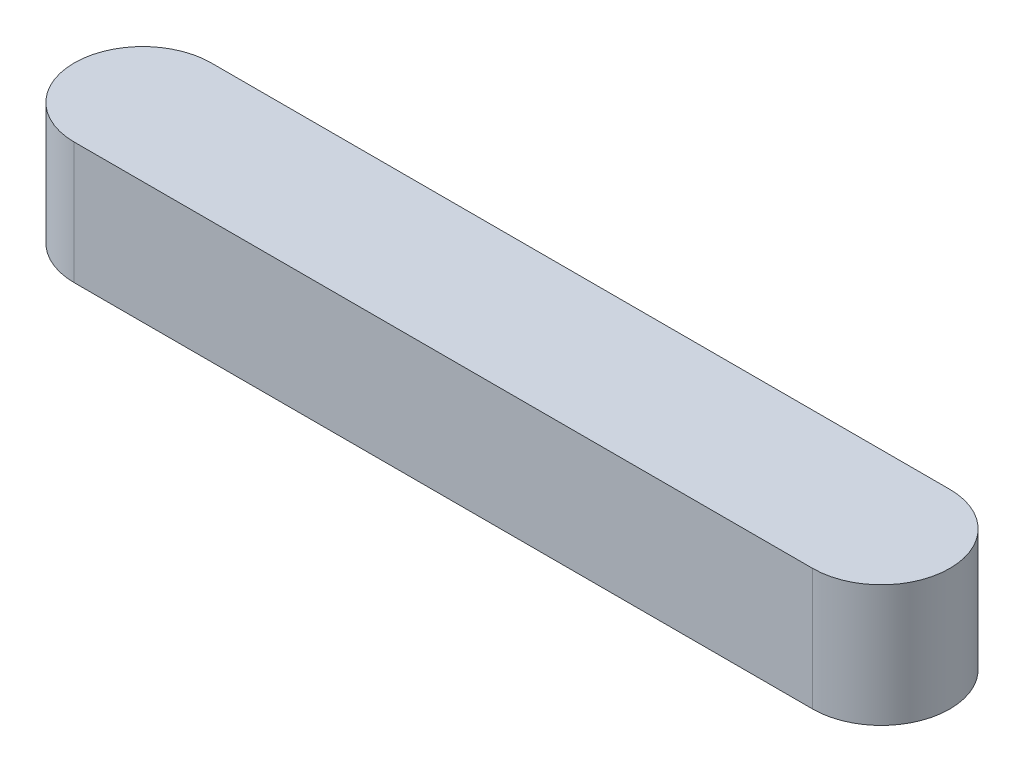
from build123d import *

# Parameters (mm, degrees)
BOSS_EXTRUDE1_DEPTH = 16


with BuildPart() as part:
    # Sketch1 → Boss-Extrude1 (new body)
    with BuildSketch(Plane(origin=(0, 0, 0), x_dir=(1, 0, 0), z_dir=(0, 1, 0))):
        with BuildLine():
            Line((-48.5, 9), (48.5, 9))
            ThreePointArc((48.5, 9), (57.5, 0), (48.5, -9))
            Line((48.5, -9), (-48.5, -9))
            ThreePointArc((-48.5, -9), (-57.5, 0), (-48.5, 9))
        make_face()
    extrude(amount=BOSS_EXTRUDE1_DEPTH)


solid = part.part
